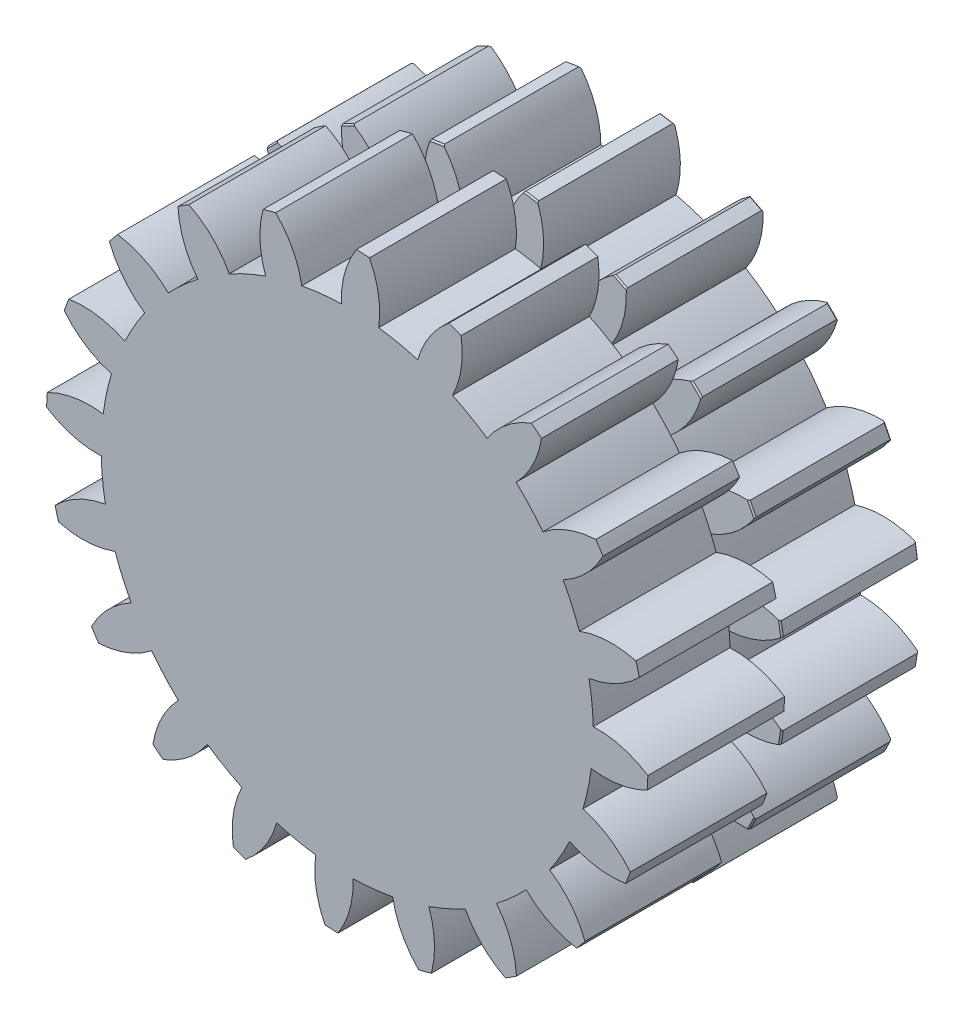
from build123d import *

# Parameters (mm, degrees)
SKETCH2_R                = 22
BOSS_EXTRUDE1_DEPTH      = 5
CUT_EXTRUDE1_DEPTH       = 10
FILLET1_R                = 0.6
CHAMFER1_SIZE            = 0.1
CIRPATTERN1_COUNT        = 20
FILLET1_OF_CIRPATTERN1_R = 0.6
CUT_EXTRUDE3_DEPTH       = 11.0000001
CIRPATTERN2_COUNT        = 20
SKETCH8_R                = 22
BOSS_EXTRUDE2_DEPTH      = 10
CUT_EXTRUDE4_DEPTH       = 10
CIRPATTERN3_COUNT        = 20
CUT_EXTRUDE5_DEPTH       = 10
CIRPATTERN4_COUNT        = 20


with BuildPart() as part:
    # Sketch2 → Boss-Extrude1 (new body, symmetric)
    with BuildSketch(Plane.XY):
        Circle(SKETCH2_R)
    extrude(amount=BOSS_EXTRUDE1_DEPTH, both=True)

    # Sketch3 → Cut-Extrude1 (cut)
    with BuildSketch(Plane.XY.offset(5)):
        with BuildLine():
            ThreePointArc((1.155064539, 17.962901378), (0, 18), (-1.155064539, 17.962901378))
            ThreePointArc((-1.155064539, 17.962901378), (-1.596564099, 20.012299891), (-2.616561789, 21.843845916))
            ThreePointArc((-2.616561789, 21.843845916), (0, 22), (2.616561789, 21.843845916))
            ThreePointArc((2.616561789, 21.843845916), (1.596564099, 20.012299891), (1.155064539, 17.962901378))
        make_face()
    cut_extrude1 = extrude(amount=-CUT_EXTRUDE1_DEPTH, mode=Mode.SUBTRACT)

    # Fillet1
    fillet1_edges = [part.edges().sort_by_distance(p)[0] for p in [
        (1.155064539, 17.962901378, 0),
        (-1.155064539, 17.962901378, 0),
    ]]
    fillet(fillet1_edges, radius=FILLET1_R)

    # Chamfer1
    chamfer1_edges = [part.edges().sort_by_distance(p)[0] for p in [
        (0, -22, -5),
        (0, -22, 5),
    ]]
    chamfer(chamfer1_edges, length=CHAMFER1_SIZE)

    # CirPattern1: Cut-Extrude1 ×20 about axis
    cirpattern1_axis = Axis((0, 0, 0), (0, 0, 1))
    for i in range(1, CIRPATTERN1_COUNT):
        add(cut_extrude1.rotate(cirpattern1_axis, i * 360 / CIRPATTERN1_COUNT), mode=Mode.SUBTRACT)

    # Fillet1 of CirPattern1
    fillet1_of_cirpattern1_edges = [part.edges().sort_by_distance(p)[0] for p in [
        (-4.452310137, 17.440668979, 0),
        (-6.649373451, 16.726799835, 0),
        (-9.623861676, 15.211222385, 0),
        (-11.49279536, 13.853362581, 0),
        (-13.853362581, 11.49279536, 0),
        (-15.211222385, 9.623861676, 0),
        (-16.726799835, 6.649373451, 0),
        (-17.440668979, 4.452310137, 0),
        (-17.962901378, 1.155064539, 0),
        (-17.962901378, -1.155064539, 0),
        (-17.440668979, -4.452310137, 0),
        (-16.726799835, -6.649373451, 0),
        (-15.211222385, -9.623861676, 0),
        (-13.853362581, -11.49279536, 0),
        (-11.49279536, -13.853362581, 0),
        (-9.623861676, -15.211222385, 0),
        (-6.649373451, -16.726799835, 0),
        (-4.452310137, -17.440668979, 0),
        (-1.155064539, -17.962901378, 0),
        (1.155064539, -17.962901378, 0),
        (4.452310137, -17.440668979, 0),
        (6.649373451, -16.726799835, 0),
        (9.623861676, -15.211222385, 0),
        (11.49279536, -13.853362581, 0),
        (13.853362581, -11.49279536, 0),
        (15.211222385, -9.623861676, 0),
        (16.726799835, -6.649373451, 0),
        (17.440668979, -4.452310137, 0),
        (17.962901378, -1.155064539, 0),
        (17.962901378, 1.155064539, 0),
        (17.440668979, 4.452310137, 0),
        (16.726799835, 6.649373451, 0),
        (15.211222385, 9.623861676, 0),
        (13.853362581, 11.49279536, 0),
        (11.49279536, 13.853362581, 0),
        (9.623861676, 15.211222385, 0),
        (6.649373451, 16.726799835, 0),
        (4.452310137, 17.440668979, 0),
    ]]
    fillet(fillet1_of_cirpattern1_edges, radius=FILLET1_OF_CIRPATTERN1_R)

    # Sketch6 → Cut-Extrude3 (cut, through all)
    with BuildSketch(Plane.XY.offset(5)):
        with BuildLine():
            Line((-2.968996641, 21.798739848), (-2.398118172, 24.056968699))
            Line((-2.398118172, 24.056968699), (2.778480736, 23.660222067))
            Line((2.778480736, 23.660222067), (2.968996641, 21.798739848))
            ThreePointArc((2.968996641, 21.798739848), (1.844757088, 19.805225799), (1.444976463, 17.55174221))
            ThreePointArc((1.444976463, 17.55174221), (0, 17.611121815), (-1.444976463, 17.55174221))
            ThreePointArc((-1.444976463, 17.55174221), (-1.844757088, 19.805225799), (-2.968996641, 21.798739848))
        make_face()
    cut_extrude3 = extrude(amount=-CUT_EXTRUDE3_DEPTH, mode=Mode.SUBTRACT)

    # CirPattern2: Cut-Extrude3 ×20 about axis
    cirpattern2_axis = Axis((0, 0, 0), (0, 0, 1))
    for i in range(1, CIRPATTERN2_COUNT):
        add(cut_extrude3.rotate(cirpattern2_axis, i * 360 / CIRPATTERN2_COUNT), mode=Mode.SUBTRACT)

    # Sketch8 → Boss-Extrude2 (add)
    with BuildSketch(Plane.XY.offset(5)):
        Circle(SKETCH8_R)
    extrude(amount=BOSS_EXTRUDE2_DEPTH)

    # Sketch9 → Cut-Extrude4 (cut)
    with BuildSketch(Plane.XY.offset(15)):
        with BuildLine():
            ThreePointArc((1.982207302, 21.910519259), (2.599115765, 19.906927465), (2.60487359, 17.810520306))
            ThreePointArc((2.60487359, 17.810520306), (3.742410435, 17.606656813), (4.864520805, 17.330217464))
            ThreePointArc((4.864520805, 17.330217464), (5.722466451, 19.243038783), (7.100974575, 20.822491688))
            ThreePointArc((7.100974575, 20.822491688), (4.574057198, 21.519247216), (1.982207302, 21.910519259))
        make_face()
    cut_extrude4 = extrude(amount=-CUT_EXTRUDE4_DEPTH, mode=Mode.SUBTRACT)

    # CirPattern3: Cut-Extrude4 ×20 about axis
    cirpattern3_axis = Axis((0, 0, 0), (0, 0, 1))
    for i in range(1, CIRPATTERN3_COUNT):
        add(cut_extrude4.rotate(cirpattern3_axis, i * 360 / CIRPATTERN3_COUNT), mode=Mode.SUBTRACT)

    # Sketch10 → Cut-Extrude5 (cut)
    with BuildSketch(Plane.XY.offset(15)):
        with BuildLine():
            Line((-5.231320947, 21.368979413), (-4.168284386, 24.021714183))
            Line((-4.168284386, 24.021714183), (0.568819764, 23.642745851))
            Line((0.568819764, 23.642745851), (0.674143392, 21.989668726))
            ThreePointArc((0.674143392, 21.989668726), (-0.186620539, 20.077977169), (-0.424626363, 17.99499076))
            ThreePointArc((-0.424626363, 17.99499076), (-1.881512339, 17.901394117), (-3.326021697, 17.690041822))
            ThreePointArc((-3.326021697, 17.690041822), (-3.991903749, 19.678025787), (-5.231320947, 21.368979413))
        make_face()
    cut_extrude5 = extrude(amount=-CUT_EXTRUDE5_DEPTH, mode=Mode.SUBTRACT)

    # CirPattern4: Cut-Extrude5 ×20 about axis
    cirpattern4_axis = Axis((0, 0, 0), (0, 0, 1))
    for i in range(1, CIRPATTERN4_COUNT):
        add(cut_extrude5.rotate(cirpattern4_axis, i * 360 / CIRPATTERN4_COUNT), mode=Mode.SUBTRACT)


solid = part.part
